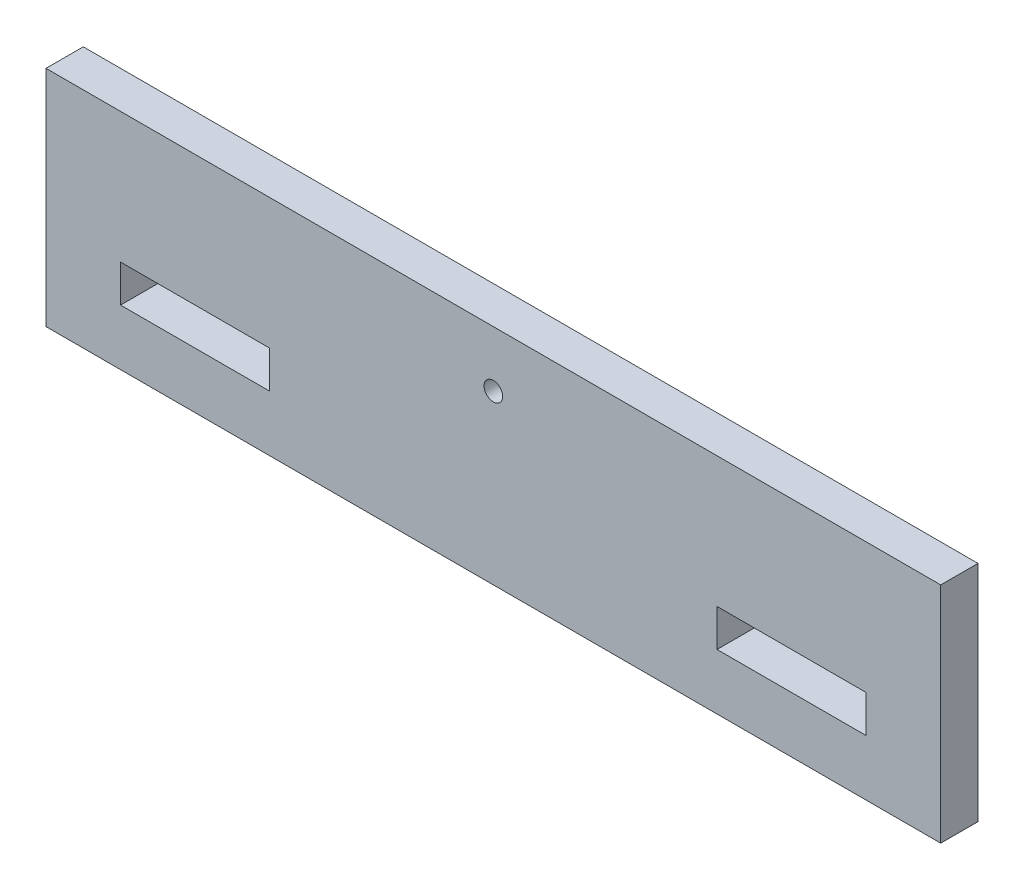
from build123d import *

# Parameters (mm, degrees)
BOSS_EXTRUDE1_DEPTH = 6.35
SKETCH2_W           = 25.4
SKETCH2_H           = 6.35
CUT_EXTRUDE1_DEPTH  = 6.35
SKETCH3_W           = 25.4
SKETCH3_H           = 6.35
CUT_EXTRUDE2_DEPTH  = 6.35
SKETCH4_R           = 1.5875
CUT_EXTRUDE4_DEPTH  = 6.35


with BuildPart() as part:
    # Sketch1 → Boss-Extrude1 (new body)
    with BuildSketch(Plane.XY):
        Polygon((6.35, 38.1), (0, 38.1), (0, 25.4), (0, 12.7), (0, 0), (6.35, 0), (146.05, 0), (152.4, 0), (152.4, 12.7), (152.4, 25.4), (152.4, 38.1), (146.05, 38.1), align=None)
    extrude(amount=BOSS_EXTRUDE1_DEPTH)

    # Sketch2 → Cut-Extrude1 (cut)
    with BuildSketch(Plane.XY.offset(6.35)):
        with Locations((25.4, 12.7)):
            Rectangle(SKETCH2_W, SKETCH2_H)
    extrude(amount=-CUT_EXTRUDE1_DEPTH, mode=Mode.SUBTRACT)

    # Sketch3 → Cut-Extrude2 (cut)
    with BuildSketch(Plane.XY.offset(6.35)):
        with Locations((127, 12.7)):
            Rectangle(SKETCH3_W, SKETCH3_H)
    extrude(amount=-CUT_EXTRUDE2_DEPTH, mode=Mode.SUBTRACT)

    # Sketch4 → Cut-Extrude4 (cut)
    with BuildSketch(Plane.XY.offset(6.35)):
        with Locations((76.2, 28.575)):
            Circle(SKETCH4_R)
    extrude(amount=-CUT_EXTRUDE4_DEPTH, mode=Mode.SUBTRACT)


solid = part.part
